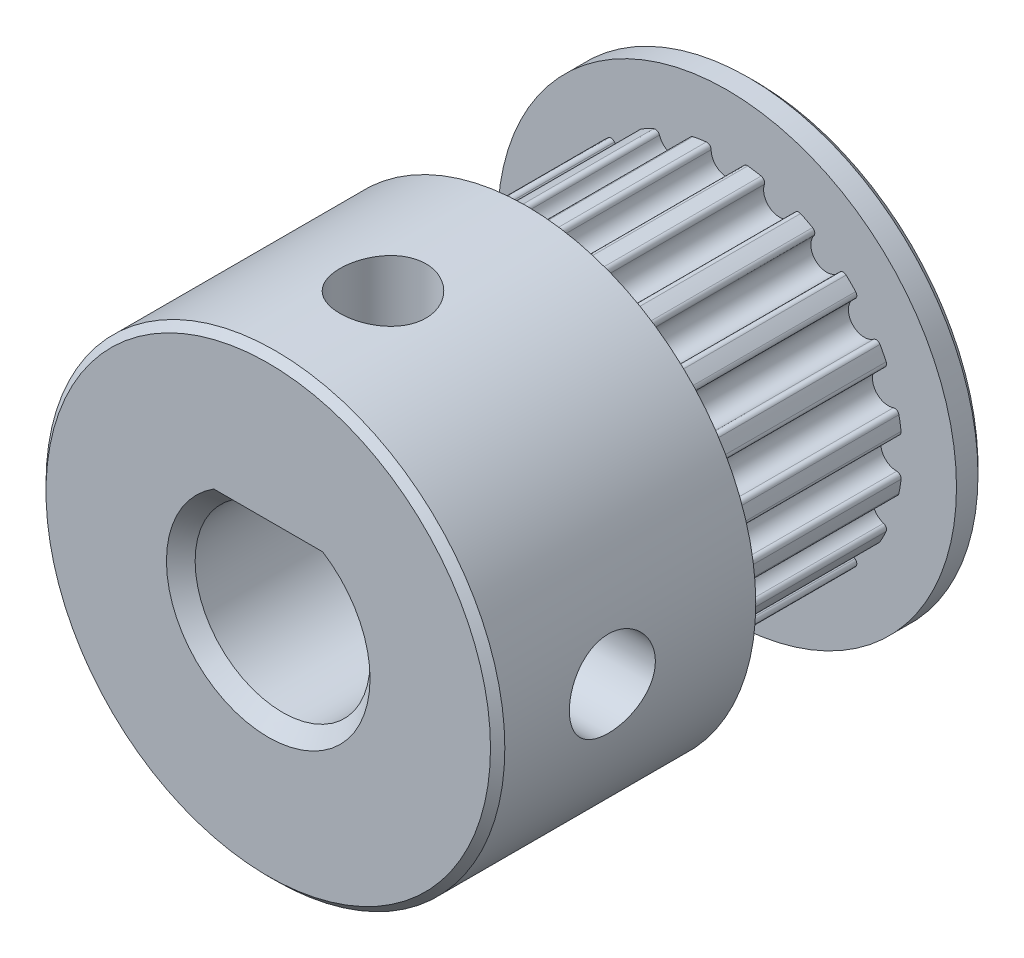
from build123d import *

# Parameters (mm, degrees)
SKETCH1_W                   = 8
SKETCH1_H                   = 1
BOSS_EXTRUDE1_DEPTH         = 7
SKETCH3_R                   = 8
BOSS_EXTRUDE2_DEPTH         = 9
CUT_EXTRUDE1_DEPTH          = 21.420577857
F_3_0_DIAMETER_HOLE1_REACH  = 24.113
F_3_0_DIAMETER_HOLE1_BORE_R = 1.5
SKETCH6_W                   = 1.5
SKETCH6_H                   = 5.5
CHAMFER1_SIZE               = 0.25
CHAMFER2_SIZE               = 0.5
FILLET1_R                   = 0.15


with BuildPart() as part:
    # Sketch1 → Revolve1 (revolve)
    with BuildSketch(Plane(origin=(0, 0, 0), x_dir=(1, 0, 0), z_dir=(0, 1, 0))):
        with Locations((4, 0.5)):
            Rectangle(SKETCH1_W, SKETCH1_H)
    revolve(axis=Axis((0, 0, -1), (0, 0, 1)))

    # Sketch2 → Boss-Extrude1 (add)
    with BuildSketch(Plane.XY):
        with BuildLine():
            ThreePointArc((0.52761747, -6.087176669), (0, -5.36), (-0.52761747, -6.087176669))
            ThreePointArc((-0.52761747, -6.087176669), (-0.955814581, -6.034775761), (-1.379247006, -5.952291802))
            ThreePointArc((-1.379247006, -5.952291802), (-1.65633109, -5.097662927), (-2.382835071, -5.626206273))
            ThreePointArc((-2.382835071, -5.626206273), (-2.773881953, -5.444049863), (-3.151101175, -5.234755141))
            ThreePointArc((-3.151101175, -5.234755141), (-3.150528952, -4.33633109), (-4.004804174, -4.614503606))
            ThreePointArc((-4.004804174, -4.614503606), (-4.320422433, -4.320422433), (-4.614503606, -4.004804174))
            ThreePointArc((-4.614503606, -4.004804174), (-4.33633109, -3.150528952), (-5.234755141, -3.151101175))
            ThreePointArc((-5.234755141, -3.151101175), (-5.444049863, -2.773881953), (-5.626206273, -2.382835071))
            ThreePointArc((-5.626206273, -2.382835071), (-5.097662927, -1.65633109), (-5.952291802, -1.379247006))
            ThreePointArc((-5.952291802, -1.379247006), (-6.034775761, -0.955814581), (-6.087176669, -0.52761747))
            ThreePointArc((-6.087176669, -0.52761747), (-5.36, 0), (-6.087176669, 0.52761747))
            ThreePointArc((-6.087176669, 0.52761747), (-6.034775761, 0.955814581), (-5.952291802, 1.379247006))
            ThreePointArc((-5.952291802, 1.379247006), (-5.097662927, 1.65633109), (-5.626206273, 2.382835071))
            ThreePointArc((-5.626206273, 2.382835071), (-5.444049863, 2.773881953), (-5.234755141, 3.151101175))
            ThreePointArc((-5.234755141, 3.151101175), (-4.33633109, 3.150528952), (-4.614503606, 4.004804174))
            ThreePointArc((-4.614503606, 4.004804174), (-4.320422433, 4.320422433), (-4.004804174, 4.614503606))
            ThreePointArc((-4.004804174, 4.614503606), (-3.150528952, 4.33633109), (-3.151101175, 5.234755141))
            ThreePointArc((-3.151101175, 5.234755141), (-2.773881953, 5.444049863), (-2.382835071, 5.626206273))
            ThreePointArc((-2.382835071, 5.626206273), (-1.65633109, 5.097662927), (-1.379247006, 5.952291802))
            ThreePointArc((-1.379247006, 5.952291802), (-0.955814581, 6.034775761), (-0.52761747, 6.087176669))
            ThreePointArc((-0.52761747, 6.087176669), (0, 5.36), (0.52761747, 6.087176669))
            ThreePointArc((0.52761747, 6.087176669), (0.955814581, 6.034775761), (1.379247006, 5.952291802))
            ThreePointArc((1.379247006, 5.952291802), (1.65633109, 5.097662927), (2.382835071, 5.626206273))
            ThreePointArc((2.382835071, 5.626206273), (2.773881953, 5.444049863), (3.151101175, 5.234755141))
            ThreePointArc((3.151101175, 5.234755141), (3.150528952, 4.33633109), (4.004804174, 4.614503606))
            ThreePointArc((4.004804174, 4.614503606), (4.320422433, 4.320422433), (4.614503606, 4.004804174))
            ThreePointArc((4.614503606, 4.004804174), (4.33633109, 3.150528952), (5.234755141, 3.151101175))
            ThreePointArc((5.234755141, 3.151101175), (5.444049863, 2.773881953), (5.626206273, 2.382835071))
            ThreePointArc((5.626206273, 2.382835071), (5.097662927, 1.65633109), (5.952291802, 1.379247006))
            ThreePointArc((5.952291802, 1.379247006), (6.034775761, 0.955814581), (6.087176669, 0.52761747))
            ThreePointArc((6.087176669, 0.52761747), (5.36, 0), (6.087176669, -0.52761747))
            ThreePointArc((6.087176669, -0.52761747), (6.034775761, -0.955814581), (5.952291802, -1.379247006))
            ThreePointArc((5.952291802, -1.379247006), (5.097662927, -1.65633109), (5.626206273, -2.382835071))
            ThreePointArc((5.626206273, -2.382835071), (5.444049863, -2.773881953), (5.234755141, -3.151101175))
            ThreePointArc((5.234755141, -3.151101175), (4.33633109, -3.150528952), (4.614503606, -4.004804174))
            ThreePointArc((4.614503606, -4.004804174), (4.320422433, -4.320422433), (4.004804174, -4.614503606))
            ThreePointArc((4.004804174, -4.614503606), (3.150528952, -4.33633109), (3.151101175, -5.234755141))
            ThreePointArc((3.151101175, -5.234755141), (2.773881953, -5.444049863), (2.382835071, -5.626206273))
            ThreePointArc((2.382835071, -5.626206273), (1.65633109, -5.097662927), (1.379247006, -5.952291802))
            ThreePointArc((1.379247006, -5.952291802), (0.955814581, -6.034775761), (0.52761747, -6.087176669))
        make_face()
    extrude(amount=BOSS_EXTRUDE1_DEPTH)

    # Sketch3 → Boss-Extrude2 (add)
    with BuildSketch(Plane(origin=(0, 0, 7), x_dir=(-1, 0, 0), z_dir=(0, 0, -1))):
        with Locations(Location((0, 0, 0), (0, 0, 180))):
            Circle(SKETCH3_R)
    extrude(amount=-BOSS_EXTRUDE2_DEPTH)

    # Sketch4 → Cut-Extrude1 (cut, through all)
    with BuildSketch(Plane.XY.offset(16)):
        with BuildLine():
            Line((1.747140521, 2.5), (-1.747140521, 2.5))
            ThreePointArc((-1.747140521, 2.5), (0, -3.05), (1.747140521, 2.5))
        make_face()
    extrude(amount=-CUT_EXTRUDE1_DEPTH, mode=Mode.SUBTRACT)

    # Ø3.0 Diameter Hole1 bore (on position points) → Ø3.0 Diameter Hole1 (cut, up to next)
    with BuildSketch(Plane(origin=(8, 0, 12), x_dir=(0, 1, 0), z_dir=(1, 0, 0)), mode=Mode.PRIVATE) as f_3_0_diameter_hole1_sk1:
        Circle(F_3_0_DIAMETER_HOLE1_BORE_R)
    f_3_0_diameter_hole1_tool1 = extrude(f_3_0_diameter_hole1_sk1.sketch, amount=-F_3_0_DIAMETER_HOLE1_REACH, mode=Mode.PRIVATE) & part.part
    add(f_3_0_diameter_hole1_tool1.solids().sort_by_distance((8, 0, 12))[0], mode=Mode.SUBTRACT)

    # Sketch6 → Ø3.0) Diameter Hole2 (revolve, cut)
    with BuildSketch(Plane(origin=(0, 2.5, 12), x_dir=(0, 0, -1), z_dir=(1, 0, 0))):
        with Locations((0.75, 2.75)):
            Rectangle(SKETCH6_W, SKETCH6_H)
    revolve(axis=Axis((0, -3.85, 12), (0, 1, 0)), mode=Mode.SUBTRACT)

    # Chamfer1
    chamfer1_edges = [part.edges().sort_by_distance(p)[0] for p in [
        (-8, 0, 16),
        (-8, 0, -1),
    ]]
    chamfer(chamfer1_edges, length=CHAMFER1_SIZE)

    # Chamfer2
    chamfer2_edges = [part.edges().sort_by_distance(p)[0] for p in [
        (0, -3.05, -1),
        (0, 2.5, -1),
        (0, -3.05, 16),
        (0, 2.5, 16),
    ]]
    chamfer(chamfer2_edges, length=CHAMFER2_SIZE)

    # Fillet1
    fillet1_edges = [part.edges().sort_by_distance(p)[0] for p in [
        (0.52761747, -6.087176669, 3.5),
        (1.379247006, -5.952291802, 3.5),
        (2.382835071, -5.626206273, 3.5),
        (3.151101175, -5.234755141, 3.5),
        (4.004804174, -4.614503606, 3.5),
        (4.614503606, -4.004804174, 3.5),
        (5.234755141, -3.151101175, 3.5),
        (5.626206273, -2.382835071, 3.5),
        (5.952291802, -1.379247006, 3.5),
        (6.087176669, -0.52761747, 3.5),
        (6.087176669, 0.52761747, 3.5),
        (5.952291802, 1.379247006, 3.5),
        (5.626206273, 2.382835071, 3.5),
        (5.234755141, 3.151101175, 3.5),
        (4.614503606, 4.004804174, 3.5),
        (4.004804174, 4.614503606, 3.5),
        (3.151101175, 5.234755141, 3.5),
        (2.382835071, 5.626206273, 3.5),
        (1.379247006, 5.952291802, 3.5),
        (0.52761747, 6.087176669, 3.5),
        (-0.52761747, 6.087176669, 3.5),
        (-1.379247006, 5.952291802, 3.5),
        (-2.382835071, 5.626206273, 3.5),
        (-3.151101175, 5.234755141, 3.5),
        (-4.004804174, 4.614503606, 3.5),
        (-4.614503606, 4.004804174, 3.5),
        (-5.234755141, 3.151101175, 3.5),
        (-5.626206273, 2.382835071, 3.5),
        (-5.952291802, 1.379247006, 3.5),
        (-6.087176669, 0.52761747, 3.5),
        (-6.087176669, -0.52761747, 3.5),
        (-5.952291802, -1.379247006, 3.5),
        (-5.626206273, -2.382835071, 3.5),
        (-5.234755141, -3.151101175, 3.5),
        (-4.614503606, -4.004804174, 3.5),
        (-4.004804174, -4.614503606, 3.5),
        (-3.151101175, -5.234755141, 3.5),
        (-2.382835071, -5.626206273, 3.5),
        (-1.379247006, -5.952291802, 3.5),
        (-0.52761747, -6.087176669, 3.5),
    ]]
    fillet(fillet1_edges, radius=FILLET1_R)


solid = part.part
